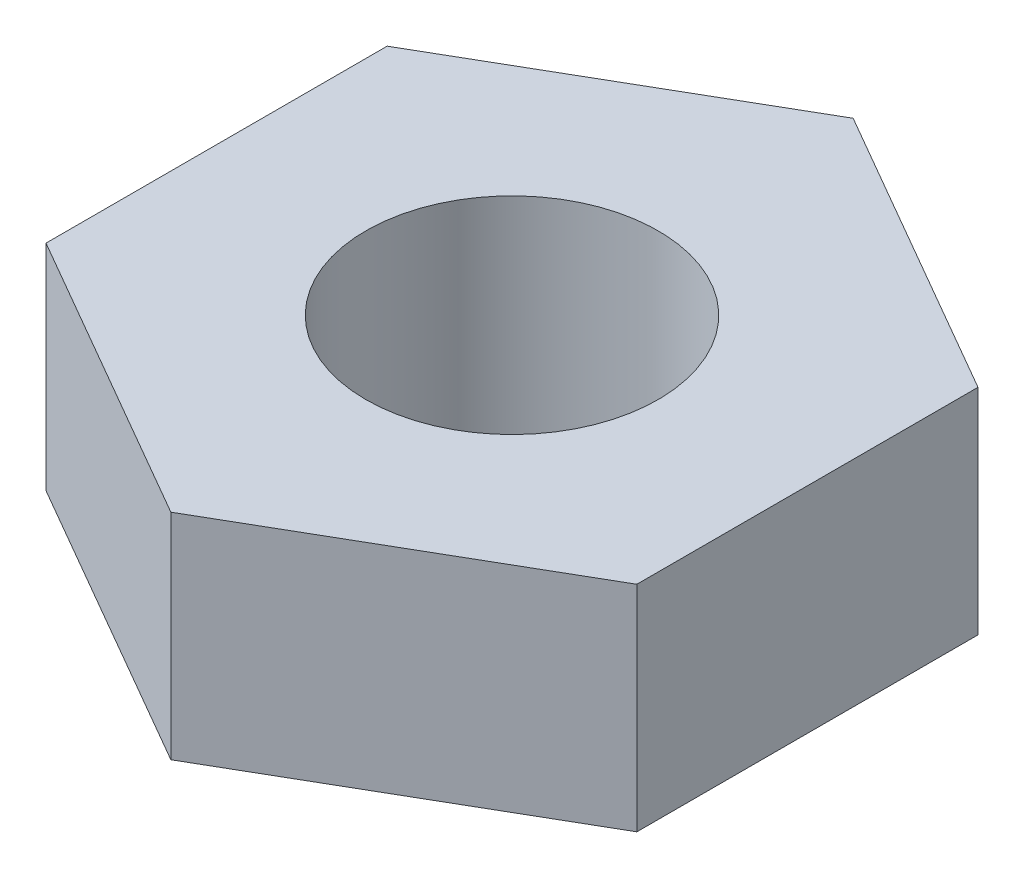
from build123d import *

# Parameters (mm, degrees)
SKETCH1_R           = 15
BOSS_EXTRUDE1_DEPTH = 22
SCALE1_SCALE        = 0.1


with BuildPart() as part:
    # Sketch1 → Boss-Extrude1 (new body)
    with BuildSketch(Plane(origin=(0, 0, 0), x_dir=(1, 0, 0), z_dir=(0, 1, 0))):
        Polygon((17.033110265, -5.228113471), (17.033110265, 29.771886529), (-13.277778868, 47.271886529), (-43.588668, 29.771886529), (-43.588668, -5.228113471), (-13.277778868, -22.728113471), align=None)
        with Locations((-13.277778868, 12.271886529)):
            Circle(SKETCH1_R, mode=Mode.SUBTRACT)
    extrude(amount=BOSS_EXTRUDE1_DEPTH)


with BuildPart() as part_1:
    # Scale1: scaled about (-13.277778868, 11, -12.271886529)
    add(part.part.scale(SCALE1_SCALE).moved(Location((-11.950000981, 9.9, -11.044697876))))


solid = part_1.part
